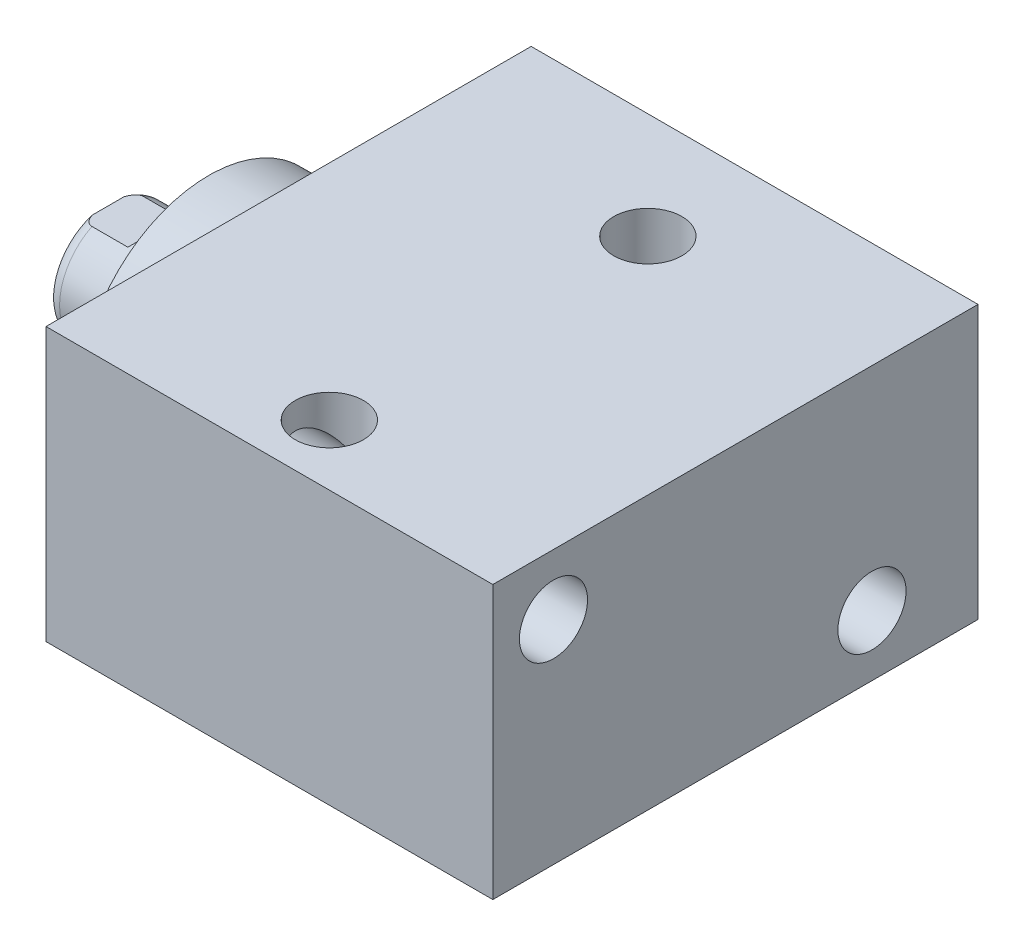
from build123d import *

# Parameters (mm, degrees)
SKETCH1_W          = 50.8
SKETCH1_H          = 28.575
EXTRUDE1_DEPTH     = 46.7868
LPATTERN1_COUNT    = 2
LPATTERN1_PITCH    = 27.94
SKETCH5_R          = 13.5001
EXTRUDE2_DEPTH     = 5.969
SKETCH6_W          = 6.3373
SKETCH6_H          = 10.541
CUT_EXTRUDE4_DEPTH = 30.48
HOLE1_D            = 7.137
HOLE1_DEPTH        = 46.7868
HOLE2_D            = 7.137
HOLE2_DEPTH        = 28.575


with BuildPart() as part:
    # Sketch1 → Extrude1 (new body)
    with BuildSketch(Plane(origin=(0, 0, 0), x_dir=(0, 0, -1), z_dir=(1, 0, 0))):
        with Locations((2.3876, 0)):
            Rectangle(SKETCH1_W, SKETCH1_H)
    extrude(amount=EXTRUDE1_DEPTH)

    # S2D0002 → Cut-Revolve1 (revolve, cut)
    with BuildSketch(Plane(origin=(0, 4.7625, 0), x_dir=(-1, 0, 0), z_dir=(0, 1, 0)), mode=Mode.PRIVATE) as cut_revolve1_sk:
        Polygon((-14.5415, -27.5336), (-18.161, -27.5336), (-18.161, -27.7876), (-9.525, -27.7876), (-9.525, -14.0716), (-13.9446, -14.0716), (-13.9446, -26.9113), (-14.5415, -27.5082), align=None)
    cut_revolve1 = revolve(cut_revolve1_sk.sketch.rotate(Axis((9.525, 4.7625, -19.13842003), (0, 0, 1)), 180), axis=Axis((9.525, 4.7625, -19.13842003), (0, 0, 1)), mode=Mode.SUBTRACT)  # turned: the seam where the file's is

    # LPattern1: Cut-Revolve1 ×2
    with Locations(*[(i * LPATTERN1_PITCH, 0, 0) for i in range(1, LPATTERN1_COUNT)]):
        add(cut_revolve1, mode=Mode.SUBTRACT)

    # Sketch5 → Extrude2 (add)
    with BuildSketch(Plane.ZY):
        Circle(SKETCH5_R)
    extrude(amount=EXTRUDE2_DEPTH)

    # Sketch6 → Revolve1 (revolve)
    with BuildSketch(Plane(origin=(0, 0, 0), x_dir=(0, 0, 1), z_dir=(0, -1, 0)), mode=Mode.PRIVATE) as revolve1_sk:
        with Locations((-3.16865, 11.2395)):
            Rectangle(SKETCH6_W, SKETCH6_H)
    revolve(revolve1_sk.sketch.rotate(Axis((5.754582971, 0, 0), (-1, 0, 0)), 180), axis=Axis((5.754582971, 0, 0), (-1, 0, 0)))  # turned: the seam where the file's is

    # S2D0001 → Cut-Revolve4 (revolve, cut)
    with BuildSketch(Plane(origin=(-18.511260017, 3.2639, 0), x_dir=(0, 1, 0), z_dir=(0, 0, 1)), mode=Mode.PRIVATE) as cut_revolve4_sk:
        Polygon((-0.7493, -3.365076823), (-0.7493, -18.003260017), (-3.2639, -19.51418413), (-3.2639, -2.001260017), (0.0381, -2.001260017), align=None)
    revolve(cut_revolve4_sk.sketch.rotate(Axis((0, 0, 0), (-1, 0, 0)), 90), axis=Axis((0, 0, 0), (-1, 0, 0)), mode=Mode.SUBTRACT)  # turned: the seam where the file's is

    # Sketch8 → Cut-Revolve5 (revolve, cut)
    with BuildSketch(Plane(origin=(0, 0, 0), x_dir=(0, 0, -1), z_dir=(0, 1, 0)), mode=Mode.PRIVATE) as cut_revolve5_sk:
        with BuildLine():
            Line((-6.3373, 10.1854), (-6.096, 10.9474))
            Line((-6.096, 10.9474), (-6.096, 15.494))
            ThreePointArc((-6.096, 15.494), (-5.995678675, 16.037796865), (-5.707922533, 16.51))
            Line((-5.707922533, 16.51), (-6.3373, 16.51))
            Line((-6.3373, 16.51), (-6.3373, 10.1854))
        make_face()
    revolve(cut_revolve5_sk.sketch.rotate(Axis((-12.65936, 0, 0), (-1, 0, 0)), 180), axis=Axis((-12.65936, 0, 0), (-1, 0, 0)), mode=Mode.SUBTRACT)  # turned: the seam where the file's is

    # Sketch12 → Cut-Extrude4 (cut, symmetric)
    with BuildSketch(Plane(origin=(0, 0, 0), x_dir=(0, -1, 0), z_dir=(0, 0, -1))):
        Polygon((5.461, 16.51), (5.461, 11.7348), (6.096, 11.0998), (6.096, 16.51), align=None)
        Polygon((-5.461, 16.51), (-5.461, 11.7348), (-6.096, 11.0998), (-6.096, 16.51), align=None)
    extrude(amount=CUT_EXTRUDE4_DEPTH, both=True, mode=Mode.SUBTRACT)

    # Hole1
    with Locations(Plane.ZY):
        with Locations((-16.6878, -7.9248), (16.6624, 7.9502)):
            Hole(HOLE1_D / 2, depth=HOLE1_DEPTH)

    # Hole2
    with Locations(Plane(origin=(0, 14.2875, 0), x_dir=(-1, 0, 0), z_dir=(0, 1, 0))):
        with Locations((-23.3172, -16.6878), (-23.3172, 16.6624)):
            Hole(HOLE2_D / 2, depth=HOLE2_DEPTH)


solid = part.part
